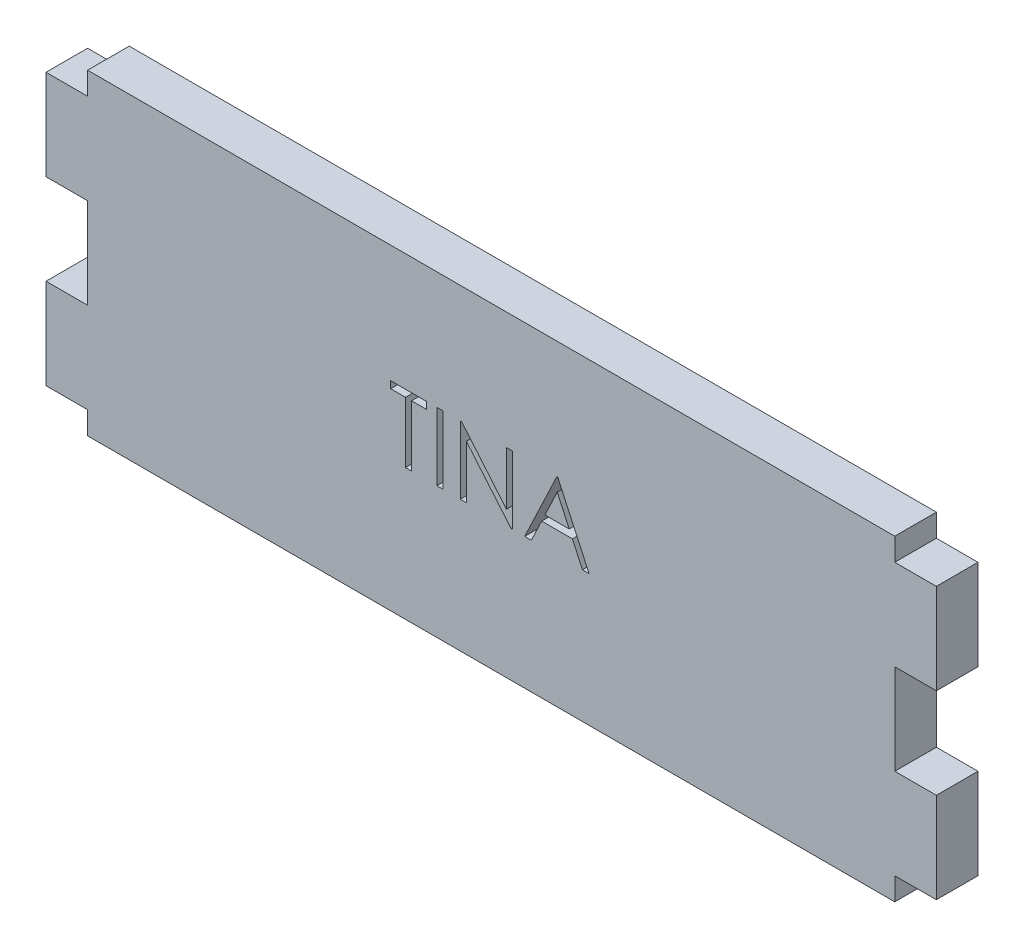
from build123d import *

# Parameters (mm, degrees)
BOSS_EXTRUDE1_DEPTH = 5.842
SKETCH2_W           = 0.854807692
SKETCH2_H           = 9.525
CUT_EXTRUDE1_DEPTH  = 3.175


with BuildPart() as part:
    # Sketch1 → Boss-Extrude1 (new body)
    with BuildSketch(Plane.XY):
        Polygon((56.642, -22.225), (-56.642, -22.225), (-56.642, -19.05), (-62.484, -19.05), (-62.484, -6.35), (-56.642, -6.35), (-56.642, 6.35), (-62.484, 6.35), (-62.484, 19.05), (-56.642, 19.05), (-56.642, 22.225), (56.642, 22.225), (56.642, 19.05), (62.484, 19.05), (62.484, 6.35), (56.642, 6.35), (56.642, -6.35), (62.484, -6.35), (62.484, -19.05), (56.642, -19.05), align=None)
    extrude(amount=BOSS_EXTRUDE1_DEPTH)

    # Sketch2 → Cut-Extrude1 (cut)
    with BuildSketch(Plane.XY.offset(5.842)):
        Polygon((-14.104326923, 4.772358215), (-14.104326923, 5.749281292), (-9.097596154, 5.749281292), (-9.097596154, 4.772358215), (-11.173557692, 4.772358215), (-11.173557692, -3.775718708), (-12.028365385, -3.775718708), (-12.028365385, 4.772358215), align=None)
        with Locations((-7.204807692, 0.986781292)):
            Rectangle(SKETCH2_W, SKETCH2_H)
        Polygon((-4.335096154, -3.775718708), (-4.335096154, 5.749281292), (-4.155739183, 5.749281292), (2.137019231, -1.747458491), (2.137019231, 5.749281292), (2.991826923, 5.749281292), (2.991826923, -3.775718708), (2.797205529, -3.775718708), (-3.480288462, 3.7038486), (-3.480288462, -3.775718708), align=None)
        Polygon((9.341826923, 5.749281292), (13.737980769, -3.775718708), (12.808759014, -3.775718708), (11.400615986, -0.722834092), (7.082692308, -0.722834092), (5.634480168, -3.775718708), (4.701442308, -3.775718708), (9.219711538, 5.749281292), align=None)
        Polygon((9.271228966, 3.892745835), (7.546349159, 0.254088984), (10.950315505, 0.254088984), align=None, mode=Mode.SUBTRACT)
    extrude(amount=-CUT_EXTRUDE1_DEPTH, mode=Mode.SUBTRACT)


solid = part.part
